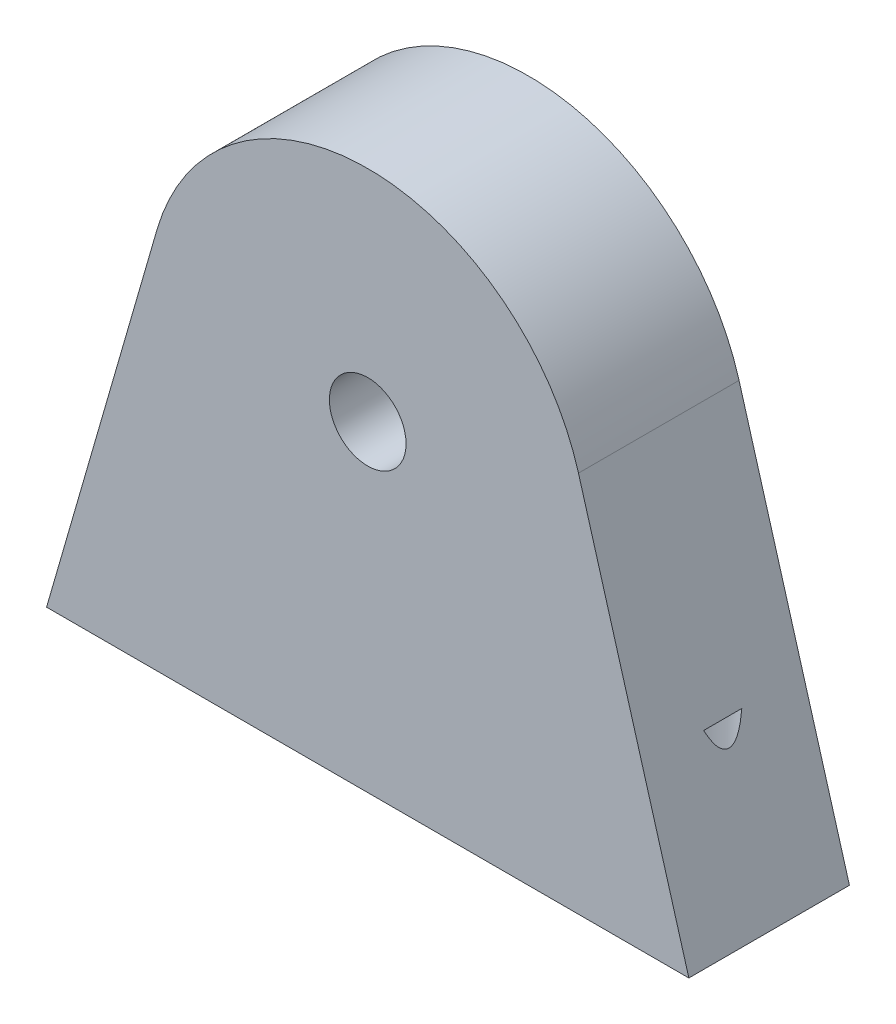
from build123d import *

# Parameters (mm, degrees)
SKETCH2_R           = 2.3876
BOSS_EXTRUDE1_DEPTH = 5
SKETCH3_R           = 2
CUT_EXTRUDE1_DEPTH  = 10


with BuildPart() as part:
    # Sketch2 → Boss-Extrude1 (new body, symmetric)
    with BuildSketch(Plane.XY):
        with BuildLine():
            Line((-20, 0), (20, 0))
            Line((20, 0), (13.124848139, 23.792582213))
            ThreePointArc((13.124848139, 23.792582213), (0, 33.661819737), (-13.124848139, 23.792582213))
            Line((-13.124848139, 23.792582213), (-20, 0))
        make_face()
        with Locations((0, 20)):
            Circle(SKETCH2_R, mode=Mode.SUBTRACT)
    extrude(amount=BOSS_EXTRUDE1_DEPTH, both=True)

    # Sketch3 → Cut-Extrude1 (cut)
    with BuildSketch(Plane(origin=(0, 0, 0), x_dir=(-1, 0, 0), z_dir=(0, -1, 0))):
        with Locations((15.5, 0)):
            Circle(SKETCH3_R)
        with Locations((-15.5, 0)):
            Circle(SKETCH3_R)
    extrude(amount=-CUT_EXTRUDE1_DEPTH, mode=Mode.SUBTRACT)


solid = part.part
